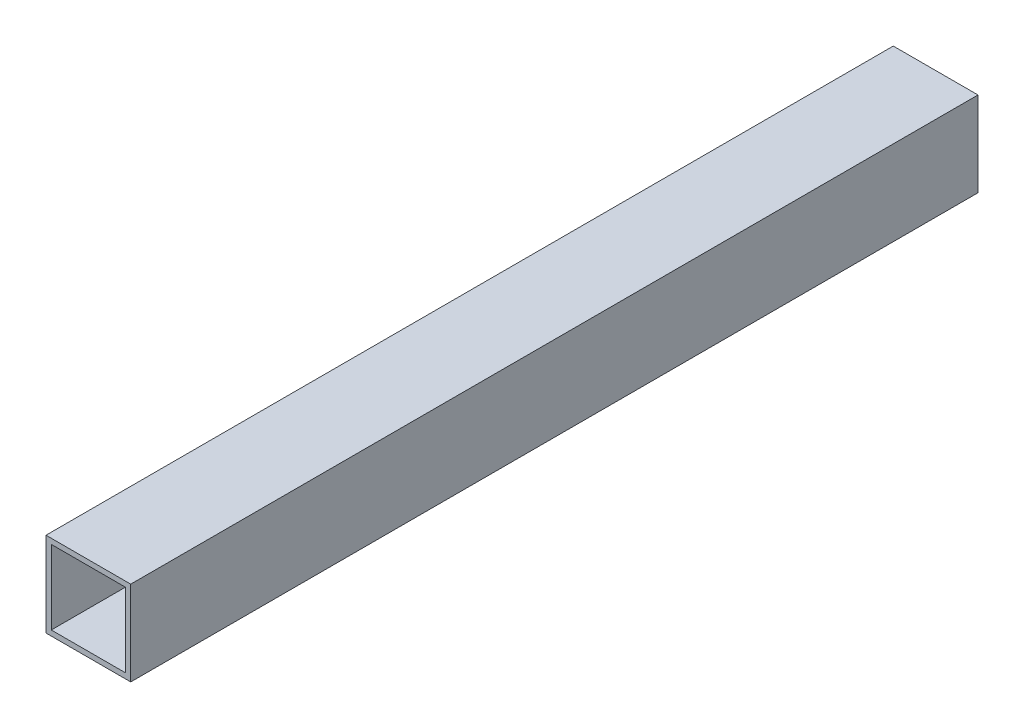
from build123d import *

# Parameters (mm, degrees)
SKETCH1_W           = 50.8
SKETCH1_H           = 50.8
SKETCH1_W_2         = 44.45
SKETCH1_H_2         = 44.45
BOSS_EXTRUDE1_DEPTH = 508


with BuildPart() as part:
    # Sketch1 → Boss-Extrude1 (new body)
    with BuildSketch(Plane.XY):
        with Locations((25.4, 25.4)):
            Rectangle(SKETCH1_W, SKETCH1_H)
        with Locations((25.4, 25.4)):
            Rectangle(SKETCH1_W_2, SKETCH1_H_2, mode=Mode.SUBTRACT)
    extrude(amount=BOSS_EXTRUDE1_DEPTH)


solid = part.part
